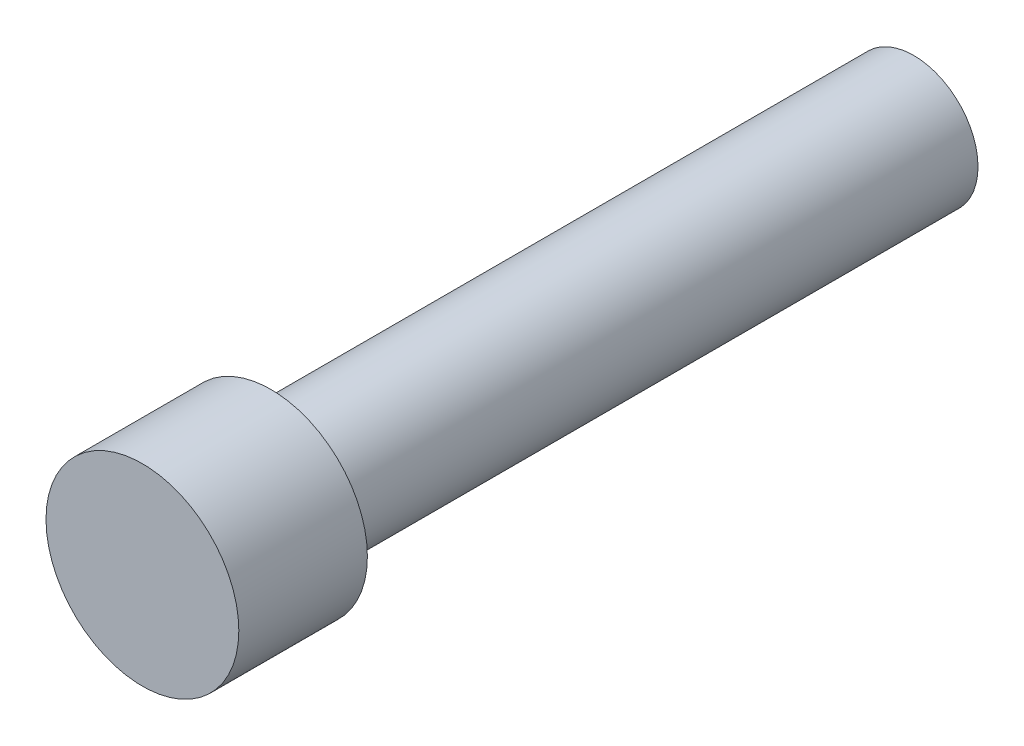
from build123d import *

# Parameters (mm, degrees)
SKETCH1_R           = 3.175
BOSS_EXTRUDE1_DEPTH = 31.75
SKETCH2_R           = 4.7625
BOSS_EXTRUDE2_DEPTH = 6.35


with BuildPart() as part:
    # Sketch1 → Boss-Extrude1 (new body)
    with BuildSketch(Plane.XY):
        Circle(SKETCH1_R)
    extrude(amount=BOSS_EXTRUDE1_DEPTH)

    # Sketch2 → Boss-Extrude2 (add)
    with BuildSketch(Plane.XY.offset(31.75)):
        Circle(SKETCH2_R)
    extrude(amount=BOSS_EXTRUDE2_DEPTH)


solid = part.part
